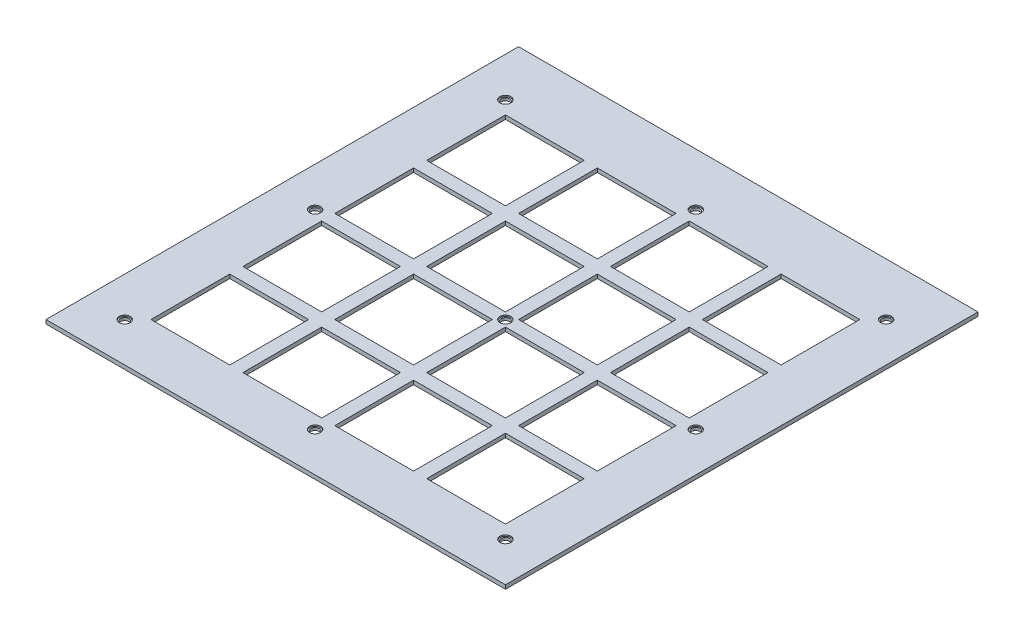
from build123d import *

# Parameters (mm, degrees)
ESQUISSE1_W                     = 350
ESQUISSE1_H                     = 360
ESQUISSE1_W_2                   = 60
ESQUISSE1_H_2                   = 60
BOSS_EXTRU_1_DEPTH              = 3
ESQUISSE2_R                     = 3.175
ENL_V_MAT_EXTRU_1_DEPTH         = 5
ESQUISSE2_2_R                   = 4.175
ESQUISSE2_2_R_2                 = 3.175
ENL_V_DE_MAT_EXTRU_MINCE1_DEPTH = 1


with BuildPart() as part:
    # Esquisse1 → Boss.-Extru.1 (new body)
    with BuildSketch(Plane(origin=(0, 0, 0), x_dir=(1, 0, 0), z_dir=(0, 1, 0))):
        with Locations((155, 160)):
            Rectangle(ESQUISSE1_W, ESQUISSE1_H)
        with Locations((50, 50)):
            Rectangle(ESQUISSE1_W_2, ESQUISSE1_H_2, mode=Mode.SUBTRACT)
        with Locations((120, 50)):
            Rectangle(ESQUISSE1_W_2, ESQUISSE1_H_2, mode=Mode.SUBTRACT)
        with Locations((50, 120)):
            Rectangle(ESQUISSE1_W_2, ESQUISSE1_H_2, mode=Mode.SUBTRACT)
        with Locations((120, 120)):
            Rectangle(ESQUISSE1_W_2, ESQUISSE1_H_2, mode=Mode.SUBTRACT)
        with Locations((190, 50)):
            Rectangle(ESQUISSE1_W_2, ESQUISSE1_H_2, mode=Mode.SUBTRACT)
        with Locations((260, 50)):
            Rectangle(ESQUISSE1_W_2, ESQUISSE1_H_2, mode=Mode.SUBTRACT)
        with Locations((190, 120)):
            Rectangle(ESQUISSE1_W_2, ESQUISSE1_H_2, mode=Mode.SUBTRACT)
        with Locations((260, 120)):
            Rectangle(ESQUISSE1_W_2, ESQUISSE1_H_2, mode=Mode.SUBTRACT)
        with Locations((50, 190)):
            Rectangle(ESQUISSE1_W_2, ESQUISSE1_H_2, mode=Mode.SUBTRACT)
        with Locations((120, 190)):
            Rectangle(ESQUISSE1_W_2, ESQUISSE1_H_2, mode=Mode.SUBTRACT)
        with Locations((50, 260)):
            Rectangle(ESQUISSE1_W_2, ESQUISSE1_H_2, mode=Mode.SUBTRACT)
        with Locations((120, 260)):
            Rectangle(ESQUISSE1_W_2, ESQUISSE1_H_2, mode=Mode.SUBTRACT)
        with Locations((190, 190)):
            Rectangle(ESQUISSE1_W_2, ESQUISSE1_H_2, mode=Mode.SUBTRACT)
        with Locations((260, 190)):
            Rectangle(ESQUISSE1_W_2, ESQUISSE1_H_2, mode=Mode.SUBTRACT)
        with Locations((190, 260)):
            Rectangle(ESQUISSE1_W_2, ESQUISSE1_H_2, mode=Mode.SUBTRACT)
        with Locations((260, 260)):
            Rectangle(ESQUISSE1_W_2, ESQUISSE1_H_2, mode=Mode.SUBTRACT)
    extrude(amount=BOSS_EXTRU_1_DEPTH)

    # Esquisse2 → Enl_v. mat.-Extru.1 (cut)
    with BuildSketch(Plane(origin=(0, 3, 0), x_dir=(1, 0, 0), z_dir=(0, 1, 0))):
        with Locations((155, 300)):
            Circle(ESQUISSE2_R)
        with Locations((10, 300)):
            Circle(ESQUISSE2_R)
        with Locations((155, 155)):
            Circle(ESQUISSE2_R)
        with Locations((300, 300)):
            Circle(ESQUISSE2_R)
        with Locations((300, 155)):
            Circle(ESQUISSE2_R)
        with Locations((10, 155)):
            Circle(ESQUISSE2_R)
        with Locations((10, 10)):
            Circle(ESQUISSE2_R)
        with Locations((300, 10)):
            Circle(ESQUISSE2_R)
        with Locations((155, 10)):
            Circle(ESQUISSE2_R)
    extrude(amount=-ENL_V_MAT_EXTRU_1_DEPTH, mode=Mode.SUBTRACT)

    # Esquisse2_2 → Enl_v. de mat.-Extru.-Mince1 (cut)
    # profile 1 of 9: a face of its own
    with BuildSketch(Plane(origin=(0, 3, 0), x_dir=(1, 0, 0), z_dir=(0, 1, 0))):
        with Locations((155, 300)):
            Circle(ESQUISSE2_2_R)
        with Locations((155, 300)):
            Circle(ESQUISSE2_2_R_2, mode=Mode.SUBTRACT)
    # profile 2 of 9: a face of its own
    with BuildSketch(Plane(origin=(0, 3, 0), x_dir=(1, 0, 0), z_dir=(0, 1, 0))):
        with Locations((10, 300)):
            Circle(ESQUISSE2_2_R)
        with Locations((10, 300)):
            Circle(ESQUISSE2_2_R_2, mode=Mode.SUBTRACT)
    # profile 3 of 9: a face of its own
    with BuildSketch(Plane(origin=(0, 3, 0), x_dir=(1, 0, 0), z_dir=(0, 1, 0))):
        with Locations((155, 155)):
            Circle(ESQUISSE2_2_R)
        with Locations((155, 155)):
            Circle(ESQUISSE2_2_R_2, mode=Mode.SUBTRACT)
    # profile 4 of 9: a face of its own
    with BuildSketch(Plane(origin=(0, 3, 0), x_dir=(1, 0, 0), z_dir=(0, 1, 0))):
        with Locations((300, 300)):
            Circle(ESQUISSE2_2_R)
        with Locations((300, 300)):
            Circle(ESQUISSE2_2_R_2, mode=Mode.SUBTRACT)
    # profile 5 of 9: a face of its own
    with BuildSketch(Plane(origin=(0, 3, 0), x_dir=(1, 0, 0), z_dir=(0, 1, 0))):
        with Locations((300, 155)):
            Circle(ESQUISSE2_2_R)
        with Locations((300, 155)):
            Circle(ESQUISSE2_2_R_2, mode=Mode.SUBTRACT)
    # profile 6 of 9: a face of its own
    with BuildSketch(Plane(origin=(0, 3, 0), x_dir=(1, 0, 0), z_dir=(0, 1, 0))):
        with Locations((10, 155)):
            Circle(ESQUISSE2_2_R)
        with Locations((10, 155)):
            Circle(ESQUISSE2_2_R_2, mode=Mode.SUBTRACT)
    # profile 7 of 9: a face of its own
    with BuildSketch(Plane(origin=(0, 3, 0), x_dir=(1, 0, 0), z_dir=(0, 1, 0))):
        with Locations((10, 10)):
            Circle(ESQUISSE2_2_R)
        with Locations((10, 10)):
            Circle(ESQUISSE2_2_R_2, mode=Mode.SUBTRACT)
    # profile 8 of 9: a face of its own
    with BuildSketch(Plane(origin=(0, 3, 0), x_dir=(1, 0, 0), z_dir=(0, 1, 0))):
        with Locations((300, 10)):
            Circle(ESQUISSE2_2_R)
        with Locations((300, 10)):
            Circle(ESQUISSE2_2_R_2, mode=Mode.SUBTRACT)
    # profile 9 of 9: a face of its own
    with BuildSketch(Plane(origin=(0, 3, 0), x_dir=(1, 0, 0), z_dir=(0, 1, 0))):
        with Locations((155, 10)):
            Circle(ESQUISSE2_2_R)
        with Locations((155, 10)):
            Circle(ESQUISSE2_2_R_2, mode=Mode.SUBTRACT)
    extrude(amount=-ENL_V_DE_MAT_EXTRU_MINCE1_DEPTH, mode=Mode.SUBTRACT)


solid = part.part
